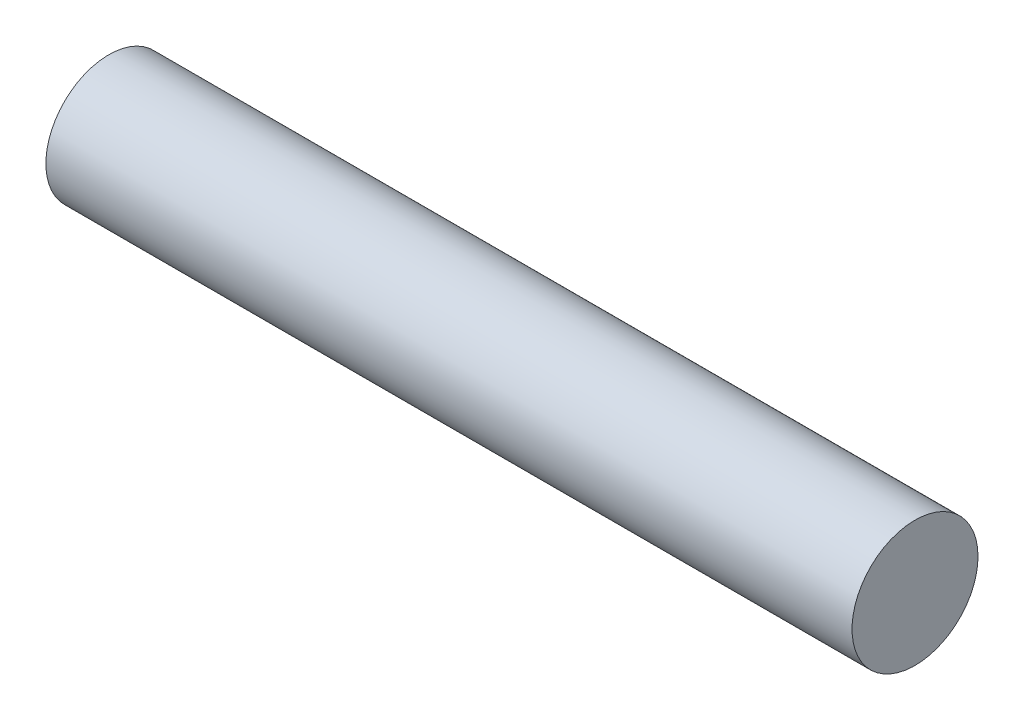
from build123d import *

# Parameters (mm, degrees)
SKETCH1_R           = 1.5875
BOSS_EXTRUDE1_DEPTH = 20.32


with BuildPart() as part:
    # Sketch1 → Boss-Extrude1 (new body)
    with BuildSketch(Plane(origin=(0, 0, 0), x_dir=(0, 0, -1), z_dir=(1, 0, 0))):
        Circle(SKETCH1_R)
    extrude(amount=BOSS_EXTRUDE1_DEPTH)


solid = part.part
